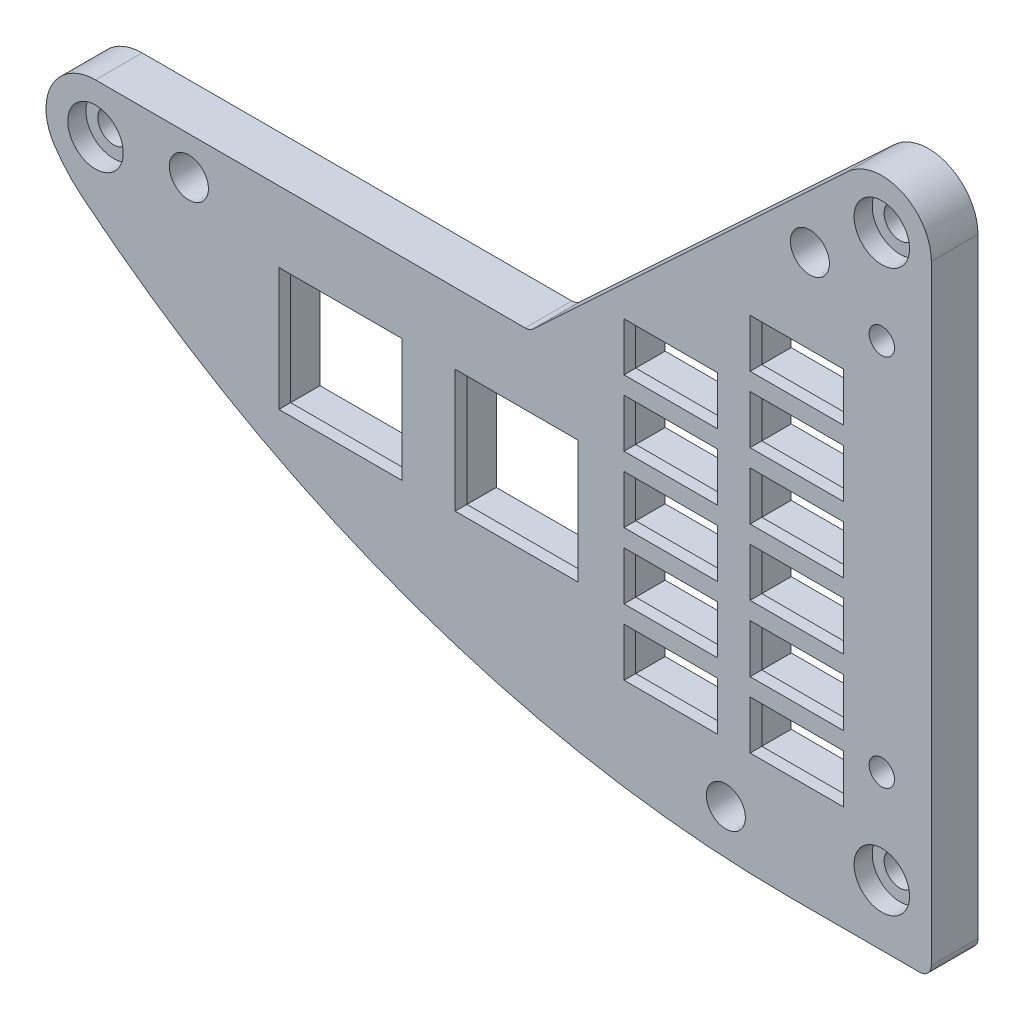
from build123d import *

# Parameters (mm, degrees)
SKETCH2_W                                       = 12.7
SKETCH2_H                                       = 6.604
SKETCH2_W_2                                     = 16.7132
SKETCH2_H_2                                     = 16.7132
BOSS_EXTRUDE1_DEPTH                             = 6.35
CBORE_FOR_6_PAN_HEAD_MACHINE_SCREW1_D           = 4.3053
CBORE_FOR_6_PAN_HEAD_MACHINE_SCREW1_CBORE_D     = 7.54126
CBORE_FOR_6_PAN_HEAD_MACHINE_SCREW1_CBORE_DEPTH = 2.4638
F_6_THREADED_INSERT_TAPERED_HOLE_AT_2_COUNT     = 2
F_6_THREADED_INSERT_TAPERED_HOLE_AT_2_PITCH     = 71.875418055
F_6_THREADED_INSERT_TAPERED_HOLE_AT_3_COUNT     = 2
F_6_THREADED_INSERT_TAPERED_HOLE_AT_3_PITCH     = 82.118347554
SKETCH7_W                                       = 16.7132
SKETCH7_H                                       = 16.7132
CUT_EXTRUDE1_DEPTH                              = 7.35
SKETCH8_W                                       = 14.224
SKETCH8_H                                       = 8.128
SKETCH8_W_2                                     = 18.2372
SKETCH8_H_2                                     = 18.2372
CUT_EXTRUDE2_DEPTH                              = 4.7625
FILLET1_R                                       = 1.5875
F_4_CLEARANCE_HOLE1_D                           = 3.4544
F_4_CLEARANCE_HOLE2_D                           = 3.4544
F_4_CLEARANCE_HOLE2_DEPTH                       = 1.5875
F_6_CLEARANCE_HOLE1_D                           = 4.3053


with BuildPart() as part:
    # Sketch2 → Boss-Extrude1 (new body)
    with BuildSketch(Plane.XY.offset(-77.851)):
        with BuildLine():
            Line((-530.586747576, 481.6475), (-530.586747576, 566.172689586))
            ThreePointArc((-530.586747576, 566.172689586), (-534.634798168, 572.345868951), (-541.909921986, 571.093898298))
            Line((-541.909921986, 571.093898298), (-585.196747576, 530.70125))
            Line((-585.196747576, 530.70125), (-644.251747576, 530.70125))
            ThreePointArc((-644.251747576, 530.70125), (-650.176036104, 527.165428624), (-649.876219443, 520.272726881))
            ThreePointArc((-649.876219443, 520.272726881), (-648.110778149, 517.987132771), (-646.019069209, 515.995782195))
            ThreePointArc((-646.019069209, 515.995782195), (-600.796684082, 490.491166469), (-549.636747576, 481.6475))
            Line((-549.636747576, 481.6475), (-530.586747576, 481.6475))
        make_face()
        with Locations((-566.019747576, 499.237)):
            Rectangle(SKETCH2_W, SKETCH2_H, mode=Mode.SUBTRACT)
        with Locations((-566.019747576, 508.2286)):
            Rectangle(SKETCH2_W, SKETCH2_H, mode=Mode.SUBTRACT)
        with Locations((-548.874747576, 499.237)):
            Rectangle(SKETCH2_W, SKETCH2_H, mode=Mode.SUBTRACT)
        with Locations((-548.874747576, 508.2286)):
            Rectangle(SKETCH2_W, SKETCH2_H, mode=Mode.SUBTRACT)
        with Locations((-548.874747576, 517.2202)):
            Rectangle(SKETCH2_W, SKETCH2_H, mode=Mode.SUBTRACT)
        with Locations((-566.019747576, 517.2202)):
            Rectangle(SKETCH2_W, SKETCH2_H, mode=Mode.SUBTRACT)
        with Locations((-566.019747576, 526.2118)):
            Rectangle(SKETCH2_W, SKETCH2_H, mode=Mode.SUBTRACT)
        with Locations((-548.874747576, 526.2118)):
            Rectangle(SKETCH2_W, SKETCH2_H, mode=Mode.SUBTRACT)
        with Locations((-548.874747576, 535.2034)):
            Rectangle(SKETCH2_W, SKETCH2_H, mode=Mode.SUBTRACT)
        with Locations((-566.019747576, 535.2034)):
            Rectangle(SKETCH2_W, SKETCH2_H, mode=Mode.SUBTRACT)
        with Locations((-548.874747576, 544.195)):
            Rectangle(SKETCH2_W, SKETCH2_H, mode=Mode.SUBTRACT)
        with Locations((-586.974747576, 512.7244)):
            Rectangle(SKETCH2_W_2, SKETCH2_H_2, mode=Mode.SUBTRACT)
    extrude(amount=-BOSS_EXTRUDE1_DEPTH)

    # CBORE for #6 Pan Head Machine Screw1 (through all)
    with Locations(Plane.XY.offset(-77.851)):
        with Locations((-537.317747576, 489.9025), (-537.317747576, 566.172689586), (-644.251747576, 523.97025)):
            CounterBoreHole(CBORE_FOR_6_PAN_HEAD_MACHINE_SCREW1_D / 2, CBORE_FOR_6_PAN_HEAD_MACHINE_SCREW1_CBORE_D / 2, CBORE_FOR_6_PAN_HEAD_MACHINE_SCREW1_CBORE_DEPTH)

    # Sketch5 → #6 Threaded Insert Tapered Hole (revolve, cut)
    with BuildSketch(Plane(origin=(-558.526747576, 487.9975, -77.851), x_dir=(0, -1, 0), z_dir=(1, 0, 0))):
        Polygon((0, 0), (0, 3.81), (2.5273, 3.81), (2.6543, 0), align=None)
    f_6_threaded_insert_tapered_hole = revolve(axis=Axis((-558.526747576, 487.9975, -187.851), (0, 0, 1)), mode=Mode.SUBTRACT)

    # #6 Threaded Insert Tapered Hole at 2: #6 Threaded Insert Tapered Hole ×2
    with Locations(*[Vector(0.159025162, 0.98727453, 0) * (i * F_6_THREADED_INSERT_TAPERED_HOLE_AT_2_PITCH) for i in range(1, F_6_THREADED_INSERT_TAPERED_HOLE_AT_2_COUNT)]):
        add(f_6_threaded_insert_tapered_hole, mode=Mode.SUBTRACT)

    # #6 Threaded Insert Tapered Hole at 3: #6 Threaded Insert Tapered Hole ×2
    with Locations(*[Vector(-0.889265337, 0.457391693, 0) * (i * F_6_THREADED_INSERT_TAPERED_HOLE_AT_3_PITCH) for i in range(1, F_6_THREADED_INSERT_TAPERED_HOLE_AT_3_COUNT)]):
        add(f_6_threaded_insert_tapered_hole, mode=Mode.SUBTRACT)

    # Sketch7 → Cut-Extrude1 (cut, through all)
    with BuildSketch(Plane.XY.offset(-77.851)):
        with Locations((-610.948497092, 512.7244)):
            Rectangle(SKETCH7_W, SKETCH7_H)
    extrude(amount=-CUT_EXTRUDE1_DEPTH, mode=Mode.SUBTRACT)

    # Sketch8 → Cut-Extrude2 (cut)
    with BuildSketch(Plane(origin=(0, 0, -84.201), x_dir=(-1, 0, 0), z_dir=(0, 0, -1))):
        with Locations((548.874747576, 544.195)):
            Rectangle(SKETCH8_W, SKETCH8_H)
        with Locations((548.874747576, 535.2034)):
            Rectangle(SKETCH8_W, SKETCH8_H)
        with Locations((548.874747576, 526.2118)):
            Rectangle(SKETCH8_W, SKETCH8_H)
        with Locations((548.874747576, 517.2202)):
            Rectangle(SKETCH8_W, SKETCH8_H)
        with Locations((548.874747576, 508.2286)):
            Rectangle(SKETCH8_W, SKETCH8_H)
        with Locations((548.874747576, 499.237)):
            Rectangle(SKETCH8_W, SKETCH8_H)
        with Locations((566.019747576, 535.2034)):
            Rectangle(SKETCH8_W, SKETCH8_H)
        with Locations((566.019747576, 526.2118)):
            Rectangle(SKETCH8_W, SKETCH8_H)
        with Locations((566.019747576, 517.2202)):
            Rectangle(SKETCH8_W, SKETCH8_H)
        with Locations((566.019747576, 508.2286)):
            Rectangle(SKETCH8_W, SKETCH8_H)
        with Locations((566.019747576, 499.237)):
            Rectangle(SKETCH8_W, SKETCH8_H)
        with Locations((586.974747576, 512.7244)):
            Rectangle(SKETCH8_W_2, SKETCH8_H_2)
        with Locations((610.948497092, 512.7244)):
            Rectangle(SKETCH8_W_2, SKETCH8_H_2)
    extrude(amount=-CUT_EXTRUDE2_DEPTH, mode=Mode.SUBTRACT)

    # Fillet1
    fillet1_edges = [part.edges().sort_by_distance(p)[0] for p in [
        (-585.196747576, 530.70125, -81.026),
        (-530.586747576, 481.6475, -81.026),
    ]]
    fillet(fillet1_edges, radius=FILLET1_R)

    # #4 Clearance Hole1 (through all)
    with Locations(Plane.XY.offset(-77.851)):
        with Locations((-537.317747576, 502.637594793), (-537.317747576, 553.437594793)):
            Hole(F_4_CLEARANCE_HOLE1_D / 2)

    # Sketch11 → Hole2 (revolve, cut)
    with BuildSketch(Plane(origin=(-642.655514401, 517.992624646, -84.201), x_dir=(0, 1, 0), z_dir=(1, 0, 0))):
        Polygon((0, 0), (0, 3.429), (1.9431, 3.429), (2.0701, 0), align=None)
    revolve(axis=Axis((-642.655514401, 517.992624646, 25.799), (0, 0, -1)), mode=Mode.SUBTRACT)

    # #4 Clearance Hole2
    with Locations(Plane(origin=(0, 0, -80.772), x_dir=(-1, 0, 0), z_dir=(0, 0, -1))):
        with Locations((642.655514401, 517.992624646)):
            Hole(F_4_CLEARANCE_HOLE2_D / 2, depth=F_4_CLEARANCE_HOLE2_DEPTH)

    # #6 Clearance Hole1 (through all)
    with Locations(Plane.XY.offset(-81.661)):
        with Locations((-558.526747576, 487.9975), (-631.551747576, 525.55775), (-547.096747576, 558.958269588)):
            Hole(F_6_CLEARANCE_HOLE1_D / 2)


solid = part.part
